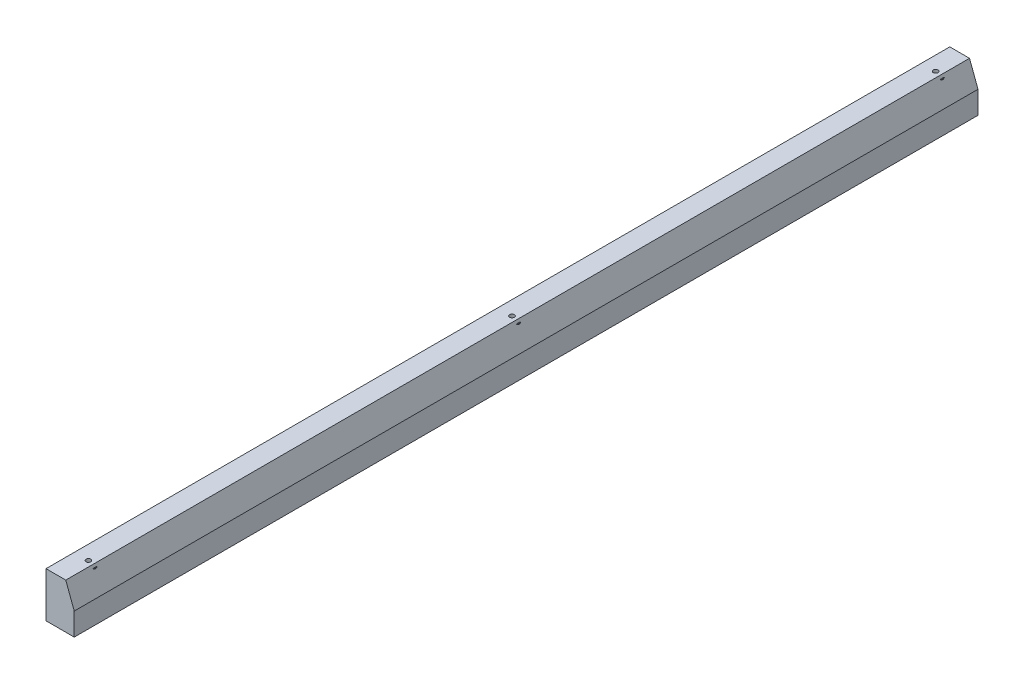
from build123d import *

# Parameters (mm, degrees)
SKETCH_1_W             = 10
SKETCH_1_H             = 16
EXTRUDE_1_DEPTH        = 320
HOLE_WIZARD_M6_1_D     = 5
HOLE_WIZARD_M6_1_DEPTH = 15
HOLE_WIZARD_M6_1_TIP   = 1.502151548
CHAMFER_1_SIZE         = 8
CHAMFER_1_SIZE2        = 3


with BuildPart() as part:
    # 草图1 → 凸台-拉伸1 (new body)
    with BuildSketch(Plane.XY):
        with Locations((5, 8)):
            Rectangle(SKETCH_1_W, SKETCH_1_H)
    extrude(amount=EXTRUDE_1_DEPTH)

    # M6 螺纹孔1
    with Locations(Plane(origin=(5, 0, 310), x_dir=(0, 0, -1), z_dir=(0, -1, 0))):
        with Locations((0, 0), (150, 0), (300, 0)):
            Hole(HOLE_WIZARD_M6_1_D / 2, depth=HOLE_WIZARD_M6_1_DEPTH)
            with Locations((0, 0, -(HOLE_WIZARD_M6_1_DEPTH + HOLE_WIZARD_M6_1_TIP / 2))):  # 118° drill point
                Cone(0, HOLE_WIZARD_M6_1_D / 2, HOLE_WIZARD_M6_1_TIP, mode=Mode.SUBTRACT)

    # 倒角1
    chamfer_1_edges = [part.edges().sort_by_distance(p)[0] for p in [
        (10, 16, 160),
    ]]
    chamfer_1_side = [part.faces().sort_by_distance(p)[0] for p in [
        (10, 8, 160),
    ]]
    chamfer(chamfer_1_edges, length=CHAMFER_1_SIZE, length2=CHAMFER_1_SIZE2, reference=chamfer_1_side[0])


solid = part.part
